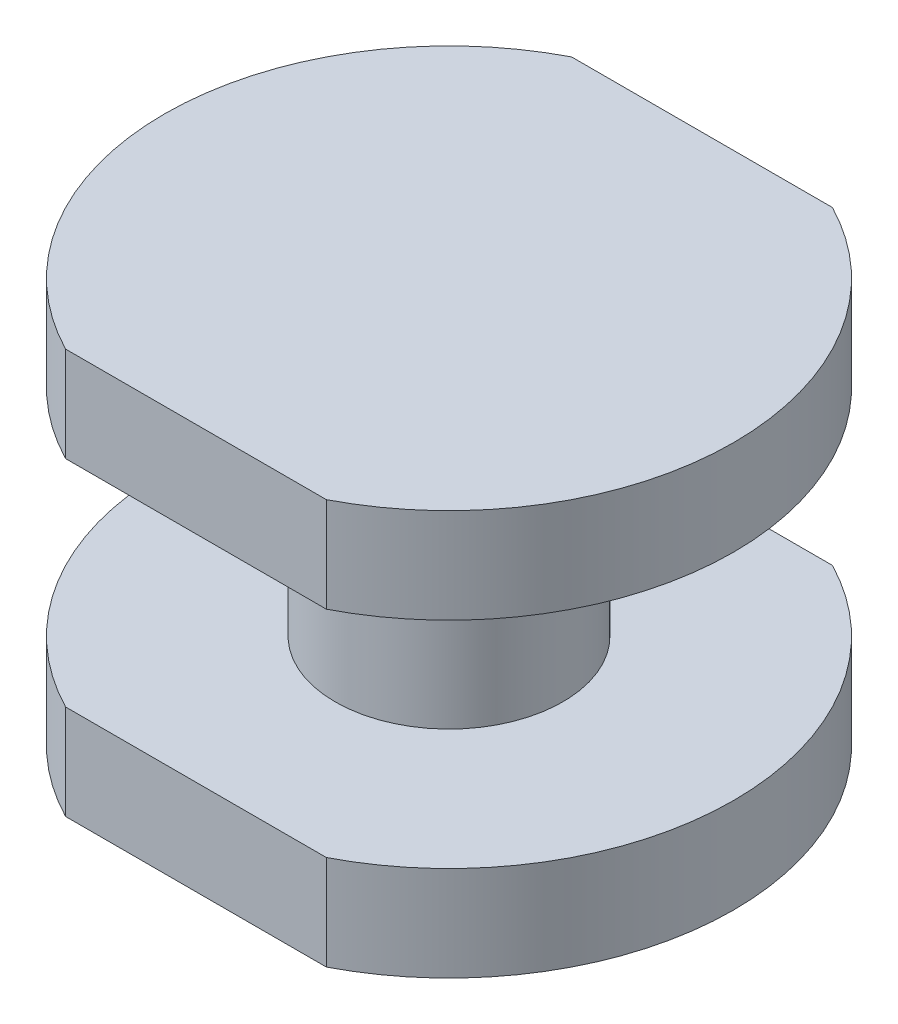
from build123d import *

# Parameters (mm, degrees)
BOSS_EXTRUDE1_DEPTH = 0.75
SKETCH2_R           = 0.9
BOSS_EXTRUDE2_DEPTH = 1.7
BOSS_EXTRUDE3_DEPTH = 0.75


with BuildPart() as part:
    # Sketch1 → Boss-Extrude1 (new body)
    with BuildSketch(Plane(origin=(0, 0, 0), x_dir=(1, 0, 0), z_dir=(0, 1, 0))):
        with BuildLine():
            Line((-1.030776406, -2), (1.030776406, -2))
            ThreePointArc((1.030776406, -2), (2.25, 0), (1.030776406, 2))
            Line((1.030776406, 2), (-1.030776406, 2))
            ThreePointArc((-1.030776406, 2), (-2.25, 0), (-1.030776406, -2))
        make_face()
    extrude(amount=BOSS_EXTRUDE1_DEPTH)

    # Sketch2 → Boss-Extrude2 (add)
    with BuildSketch(Plane(origin=(0, 0.75, 0), x_dir=(1, 0, 0), z_dir=(0, 1, 0))):
        Circle(SKETCH2_R)
    extrude(amount=BOSS_EXTRUDE2_DEPTH)

    # Sketch3 → Boss-Extrude3 (add)
    with BuildSketch(Plane(origin=(0, 2.45, 0), x_dir=(1, 0, 0), z_dir=(0, 1, 0))):
        with BuildLine():
            Line((-1.030776406, 2), (1.030776406, 2))
            ThreePointArc((1.030776406, 2), (2.25, 0), (1.030776406, -2))
            Line((1.030776406, -2), (-1.030776406, -2))
            ThreePointArc((-1.030776406, -2), (-2.25, 0), (-1.030776406, 2))
        make_face()
    extrude(amount=BOSS_EXTRUDE3_DEPTH)


solid = part.part
